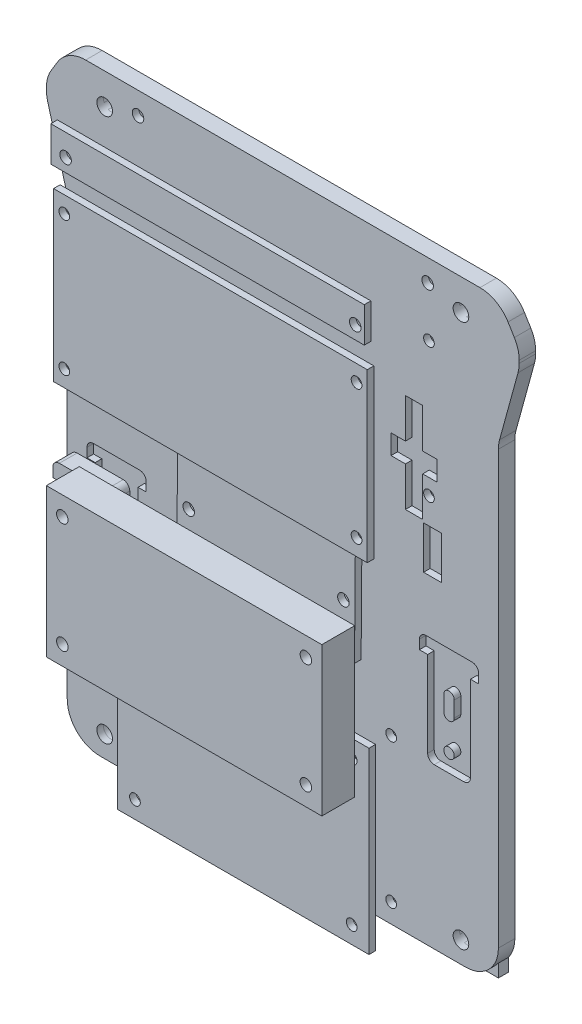
from build123d import *

# Parameters (mm, degrees)
BOSS_EXTRUDE2_DEPTH  = 5
SKETCH4_R            = 1
BATTERY_PACK_DEPTH   = 6
SKETCH5_R            = 1.625
MOTOR_MOUNTS_DEPTH   = 6
SKETCH6_R            = 1.625
MTR_CLTR_DEPTH       = 6
CASTER_R             = 1.625
FRONT_WHEEL_DEPTH    = 6
ANLG_CTLR_R          = 1.625
ANLG_CTLR_1_DEPTH    = 6
TOP_PLATE_R          = 2.3749
CUT_EXTRUDE3_DEPTH   = 6
TOP_PLATE_3_W        = 127
TOP_PLATE_3_H        = 177.8
TOP_PLATE_3_R        = 6.35
TOP_PLATE_3_R_2      = 2.3749
BOSS_EXTRUDE3_DEPTH  = 3
SENSOR_BOARD_R       = 1.75
SENSOR_DEPTH         = 6
SKETCH18_W           = 5.46
SKETCH18_H           = 13
CUT_EXTRUDE5_DEPTH   = 6
SKETCH19_R           = 1.5875
CUT_EXTRUDE6_DEPTH   = 6
BOSS_EXTRUDE5_START  = 10
SKETCH16_3_W         = 57.15
SKETCH16_3_H         = 23.114
SKETCH16_3_R         = 1.5875
BOSS_EXTRUDE5_DEPTH  = 2
BOSS_EXTRUDE6_START  = 10
SKETCH10_3_R         = 1.75
BOSS_EXTRUDE6_DEPTH  = 2
BOSS_EXTRUDE7_START  = 10
SKETCH6_2_W          = 76.36
SKETCH6_2_H          = 54.3
SKETCH6_2_R          = 1.625
BOSS_EXTRUDE7_DEPTH  = 2
BOSS_EXTRUDE8_START  = 10
SKETCH19_3_R         = 1.5875
BOSS_EXTRUDE8_DEPTH  = 5.4
BOSS_EXTRUDE9_START  = 20
SKETCH8_2_W          = 95.3
SKETCH8_2_H          = 50.81
SKETCH8_2_R          = 1.625
BOSS_EXTRUDE9_DEPTH  = 2
BOSS_EXTRUDE10_START = 20
BRD_BOARD_W          = 83.7
BRD_BOARD_H          = 45.1
BRD_BOARD_R          = 1.75
BOSS_EXTRUDE10_DEPTH = 10
BOSS_EXTRUDE11_START = -10
SKETCH7_3_W          = 38
SKETCH7_3_H          = 33
SKETCH7_3_R          = 1.625
BOSS_EXTRUDE11_DEPTH = 2
BOSS_EXTRUDE12_START = 20
SENSOR_BOARD_3_W     = 95.25
SENSOR_BOARD_3_H     = 10.65
SENSOR_BOARD_3_R     = 1.75
BOSS_EXTRUDE12_DEPTH = 2
FPGA_R               = 1.75
CUT_EXTRUDE10_DEPTH  = 36
BRD_BOARD_5_R        = 1.75
CUT_EXTRUDE11_DEPTH  = 11


with BuildPart() as part:
    # Outline1 → Boss-Extrude2 (new body)
    with BuildSketch(Plane.XY):
        with BuildLine():
            Line((-65.5, 141.268437099), (-65.5, 10))
            ThreePointArc((-65.5, 10), (-62.571067812, 2.928932188), (-55.5, 0))
            Line((-55.5, 0), (55.5, 0))
            ThreePointArc((55.5, 0), (62.571067812, 2.928932188), (65.5, 10))
            Line((65.5, 10), (65.5, 141.268437099))
            ThreePointArc((65.5, 141.268437099), (65.589402556, 142.602625355), (65.856011661, 143.912957643))
            Line((65.856011661, 143.912957643), (71.465198975, 164.368437622))
            ThreePointArc((71.465198975, 164.368437622), (71.731808079, 165.67876991), (71.821210635, 167.012958167))
            Line((71.821210635, 167.012958167), (71.821210635, 167.847824973))
            ThreePointArc((71.821210635, 167.847824973), (71.446110508, 170.560996999), (70.348950147, 173.070626791))
            Line((70.348950147, 173.070626791), (68.425788167, 176.210746783))
            ThreePointArc((68.425788167, 176.210746783), (64.785378285, 179.712279271), (59.898048656, 180.987944965))
            Line((59.898048656, 180.987944965), (-59.898048655, 180.987944965))
            ThreePointArc((-59.898048655, 180.987944965), (-64.785378285, 179.712279271), (-68.425788167, 176.210746783))
            Line((-68.425788167, 176.210746783), (-70.348950147, 173.070626791))
            ThreePointArc((-70.348950147, 173.070626791), (-71.446110508, 170.560996999), (-71.821210635, 167.847824973))
            Line((-71.821210635, 167.847824973), (-71.821210635, 167.012958167))
            ThreePointArc((-71.821210635, 167.012958167), (-71.731808079, 165.67876991), (-71.465198975, 164.368437622))
            Line((-71.465198975, 164.368437622), (-65.856011661, 143.912957643))
            ThreePointArc((-65.856011661, 143.912957643), (-65.589402556, 142.602625355), (-65.5, 141.268437099))
        make_face()
    extrude(amount=BOSS_EXTRUDE2_DEPTH)

    # Sketch4 → Battery Pack (cut, through all)
    with BuildSketch(Plane.XY.offset(5)):
        with Locations((0, 105.731791241)):
            Circle(SKETCH4_R)
        with Locations((0, 61.131791241)):
            Circle(SKETCH4_R)
        with Locations((0, 55.681791241)):
            Circle(SKETCH4_R)
        with Locations((0, 111.181791241)):
            Circle(SKETCH4_R)
    extrude(amount=-BATTERY_PACK_DEPTH, mode=Mode.SUBTRACT)

    # Sketch5 → Motor mounts (cut, through all)
    with BuildSketch(Plane.XY.offset(5)):
        Polygon((37.25, 111.277082215), (42.5, 111.277082215), (42.5, 123.277082215), (46.875, 123.277082215), (46.875, 129.277082215), (42.5, 129.277082215), (42.5, 141.277082215), (37.25, 141.277082215), (37.25, 129.277082215), (32.875, 129.277082215), (32.875, 123.277082215), (37.25, 123.277082215), align=None)
        Polygon((-37.25, 141.277082215), (-37.25, 129.277082215), (-32.875, 129.277082215), (-32.875, 123.277082215), (-37.25, 123.277082215), (-37.25, 111.277082215), (-42.5, 111.277082215), (-42.5, 123.277082215), (-46.875, 123.277082215), (-46.875, 129.277082215), (-42.5, 129.277082215), (-42.5, 141.277082215), align=None)
        with Locations((-45.5, 108.277082215)):
            Circle(SKETCH5_R)
        with Locations((-45.5, 99.777082215)):
            Circle(SKETCH5_R)
        with Locations(Location((45.5, 99.777082215, 0), (0, 0, 180))):  # turned: the seam where the file's is
            Circle(SKETCH5_R)
        with Locations(Location((45.5, 108.277082215, 0), (0, 0, 180))):  # turned: the seam where the file's is
            Circle(SKETCH5_R)
    extrude(amount=-MOTOR_MOUNTS_DEPTH, mode=Mode.SUBTRACT)

    # Sketch6 → mtr_cltr (cut, through all)
    with BuildSketch(Plane.XY.offset(5)):
        with Locations((-32.93, 49.68)):
            Circle(SKETCH6_R)
        with Locations((-32.93, 5.88)):
            Circle(SKETCH6_R)
        with Locations((32.93, 5.88)):
            Circle(SKETCH6_R)
        with Locations((32.93, 49.68)):
            Circle(SKETCH6_R)
    extrude(amount=-MTR_CLTR_DEPTH, mode=Mode.SUBTRACT)

    # Caster → Front Wheel (cut, through all)
    with BuildSketch(Plane.XY.offset(5)):
        with Locations((-15.5, 35.5)):
            Circle(CASTER_R)
        with Locations((15.5, 35.5)):
            Circle(CASTER_R)
        with Locations((15.5, 12)):
            Circle(CASTER_R)
        with Locations((-15.5, 12)):
            Circle(CASTER_R)
    extrude(amount=-FRONT_WHEEL_DEPTH, mode=Mode.SUBTRACT)

    # anlg_ctlr → anlg_ctlr.1 (cut, through all)
    with BuildSketch(Plane.XY.offset(5)):
        with Locations((-44.4, 118.467082215)):
            Circle(ANLG_CTLR_R)
        with Locations((44.4, 159.277082215)):
            Circle(ANLG_CTLR_R)
        with Locations((44.4, 118.467082215)):
            Circle(ANLG_CTLR_R)
        with Locations((-44.4, 159.277082215)):
            Circle(ANLG_CTLR_R)
    extrude(amount=-ANLG_CTLR_1_DEPTH, mode=Mode.SUBTRACT)

    # Top PlaTE → Cut-Extrude3 (cut, through all)
    with BuildSketch(Plane.XY):
        with Locations((54.125, 6.474265411)):
            Circle(TOP_PLATE_R)
        with Locations((-54.125, 171.574265411)):
            Circle(TOP_PLATE_R)
        with Locations((54.125, 171.574265411)):
            Circle(TOP_PLATE_R)
        with Locations((-54.125, 6.474265411)):
            Circle(TOP_PLATE_R)
    extrude(amount=CUT_EXTRUDE3_DEPTH, mode=Mode.SUBTRACT)

    # Sensor Board → Sensor (cut, through all)
    with BuildSketch(Plane.XY.offset(5)):
        with Locations((-44, 174.275082215)):
            Circle(SENSOR_BOARD_R)
        with Locations((44, 174.275082215)):
            Circle(SENSOR_BOARD_R)
    extrude(amount=-SENSOR_DEPTH, mode=Mode.SUBTRACT)

    # Sketch18 → Cut-Extrude5 (cut, through all)
    with BuildSketch(Plane.XY):
        with Locations((-45.5, 104.027082215)):
            Rectangle(SKETCH18_W, SKETCH18_H)
        with Locations((45.5, 104.027082215)):
            Rectangle(SKETCH18_W, SKETCH18_H)
    extrude(amount=CUT_EXTRUDE5_DEPTH, mode=Mode.SUBTRACT)

    # Sketch19 → Cut-Extrude6 (cut, through all)
    with BuildSketch(Plane.XY):
        with BuildLine():
            Line((-55, 48.501962253), (-46, 48.501962253))
            ThreePointArc((-46, 48.501962253), (-44.585786438, 49.087748691), (-44, 50.501962253))
            Line((-44, 50.501962253), (-44, 76.501962253))
            Line((-44, 76.501962253), (-57, 76.501962253))
            Line((-57, 76.501962253), (-57, 50.501962253))
            ThreePointArc((-57, 50.501962253), (-56.414213562, 49.087748691), (-55, 48.501962253))
        make_face()
        with Locations((-50.5, 53.841962253)):
            Circle(SKETCH19_R, mode=Mode.SUBTRACT)
        with BuildLine():
            ThreePointArc((-52.0875, 63.821962253), (-50.5, 62.234462253), (-48.9125, 63.821962253))
            Line((-48.9125, 63.821962253), (-48.9125, 68.569720756))
            ThreePointArc((-48.9125, 68.569720756), (-50.5, 70.157220756), (-52.0875, 68.569720756))
            Line((-52.0875, 68.569720756), (-52.0875, 63.821962253))
        make_face(mode=Mode.SUBTRACT)
        with BuildLine():
            Line((-59.5, 76.501962253), (-57, 76.501962253))
            Line((-57, 76.501962253), (-44, 76.501962253))
            Line((-44, 76.501962253), (-41.5, 76.501962253))
            Line((-41.5, 76.501962253), (-41.5, 79.264462253))
            ThreePointArc((-41.5, 79.264462253), (-42.085786438, 80.678675816), (-43.5, 81.264462253))
            Line((-43.5, 81.264462253), (-57.5, 81.264462253))
            ThreePointArc((-57.5, 81.264462253), (-58.914213562, 80.678675816), (-59.5, 79.264462253))
            Line((-59.5, 79.264462253), (-59.5, 76.501962253))
        make_face()
        with BuildLine():
            ThreePointArc((41.5, 79.264462253), (42.085786438, 80.678675816), (43.5, 81.264462253))
            Line((43.5, 81.264462253), (57.5, 81.264462253))
            ThreePointArc((57.5, 81.264462253), (58.914213562, 80.678675816), (59.5, 79.264462253))
            Line((59.5, 79.264462253), (59.5, 76.501962253))
            Line((59.5, 76.501962253), (41.5, 76.501962253))
            Line((41.5, 76.501962253), (41.5, 79.264462253))
        make_face()
        with BuildLine():
            Line((57, 76.501962253), (44, 76.501962253))
            Line((44, 76.501962253), (44, 50.501962253))
            ThreePointArc((44, 50.501962253), (44.585786438, 49.087748691), (46, 48.501962253))
            Line((46, 48.501962253), (55, 48.501962253))
            ThreePointArc((55, 48.501962253), (56.414213562, 49.087748691), (57, 50.501962253))
            Line((57, 50.501962253), (57, 76.501962253))
        make_face()
        with Locations((50.5, 53.841962253)):
            Circle(SKETCH19_R, mode=Mode.SUBTRACT)
        with BuildLine():
            Line((48.9125, 63.821962253), (48.9125, 68.569720756))
            ThreePointArc((48.9125, 68.569720756), (50.5, 70.157220756), (52.0875, 68.569720756))
            Line((52.0875, 68.569720756), (52.0875, 63.821962253))
            ThreePointArc((52.0875, 63.821962253), (50.5, 62.234462253), (48.9125, 63.821962253))
        make_face(mode=Mode.SUBTRACT)
    extrude(amount=CUT_EXTRUDE6_DEPTH, mode=Mode.SUBTRACT)


with BuildPart() as body_2:
    # Top PlaTE_3 → Boss-Extrude3 (new body)
    with BuildSketch(Plane.XY):
        with Locations((0, 89.024265411)):
            Rectangle(TOP_PLATE_3_W, TOP_PLATE_3_H)
        with Locations((-53.34, 50.924265411)):
            Circle(TOP_PLATE_3_R, mode=Mode.SUBTRACT)
        with Locations((54.125, 6.474265411)):
            Circle(TOP_PLATE_3_R_2, mode=Mode.SUBTRACT)
        with Locations((-54.125, 171.574265411)):
            Circle(TOP_PLATE_3_R_2, mode=Mode.SUBTRACT)
        with Locations((54.125, 171.574265411)):
            Circle(TOP_PLATE_3_R_2, mode=Mode.SUBTRACT)
        with Locations((-54.125, 6.474265411)):
            Circle(TOP_PLATE_3_R_2, mode=Mode.SUBTRACT)
    extrude(amount=BOSS_EXTRUDE3_DEPTH)

    # FPGA → Cut-Extrude10 (cut, through all)
    with BuildSketch(Plane.XY):
        with Locations((-34, 169.658814415)):
            Circle(FPGA_R)
        with Locations((34, 169.658814415)):
            Circle(FPGA_R)
        with Locations((34, 101.658814415)):
            Circle(FPGA_R)
        with Locations((-34, 101.658814415)):
            Circle(FPGA_R)
    extrude(amount=CUT_EXTRUDE10_DEPTH, mode=Mode.SUBTRACT)

    # brd_board_5 → Cut-Extrude11 (cut, through all)
    with BuildSketch(Plane.XY.offset(5)):
        with Locations((37, 53.718812762)):
            Circle(BRD_BOARD_5_R)
        with Locations((-37, 53.718812762)):
            Circle(BRD_BOARD_5_R)
        with Locations((-37, 87.218812762)):
            Circle(BRD_BOARD_5_R)
        with Locations((37, 87.218812762)):
            Circle(BRD_BOARD_5_R)
    extrude(amount=-CUT_EXTRUDE11_DEPTH, mode=Mode.SUBTRACT)


with BuildPart() as body_3:
    # Sketch16_3 → Boss-Extrude5 (new body)
    with BuildSketch(Plane.XY.offset(BOSS_EXTRUDE5_START)):
        with Locations((0, 36.625433673)):
            Rectangle(SKETCH16_3_W, SKETCH16_3_H)
        with Locations((-25.908, 45.007433673)):
            Circle(SKETCH16_3_R, mode=Mode.SUBTRACT)
        with Locations((25.908, 45.007433673)):
            Circle(SKETCH16_3_R, mode=Mode.SUBTRACT)
        with Locations((25.908, 28.243433673)):
            Circle(SKETCH16_3_R, mode=Mode.SUBTRACT)
        with Locations((-25.908, 28.243433673)):
            Circle(SKETCH16_3_R, mode=Mode.SUBTRACT)
    extrude(amount=BOSS_EXTRUDE5_DEPTH)


with BuildPart() as body_4:
    # Sketch10_3 → Boss-Extrude6 (new body)
    with BuildSketch(Plane.XY.offset(BOSS_EXTRUDE6_START)):
        Polygon((-25.211498717, 70.476976171), (-15.961785964, 70.404079055), (-16.011040772, 64.154273141), (-3.761421181, 64.057733717), (-3.712166372, 70.307539631), (15.787228079, 70.15386463), (15.771466541, 68.153926737), (24.771187057, 68.082999813), (24.786948596, 70.082937706), (28.786824381, 70.051414628), (29.306955155, 136.049365081), (26.557040553, 136.071037197), (23.703801948, 138.843609011), (-9.295173278, 139.103674398), (-12.191756114, 136.376417008), (-24.691367942, 136.474926624), align=None)
        with Locations((25.405144609, 85.078531515)):
            Circle(SKETCH10_3_R, mode=Mode.SUBTRACT)
        with Locations((-21.593395865, 85.448927673)):
            Circle(SKETCH10_3_R, mode=Mode.SUBTRACT)
        with Locations((-6.686016333, 137.083049486)):
            Circle(SKETCH10_3_R, mode=Mode.SUBTRACT)
        with Locations((21.813098635, 136.858447561)):
            Circle(SKETCH10_3_R, mode=Mode.SUBTRACT)
    extrude(amount=BOSS_EXTRUDE6_DEPTH)


with BuildPart() as body_5:
    # Sketch6_2 → Boss-Extrude7 (new body)
    with BuildSketch(Plane.XY.offset(5).offset(BOSS_EXTRUDE7_START)):
        with Locations((0, 27.78)):
            Rectangle(SKETCH6_2_W, SKETCH6_2_H)
        with Locations((-32.93, 49.68)):
            Circle(SKETCH6_2_R, mode=Mode.SUBTRACT)
        with Locations((32.93, 49.68)):
            Circle(SKETCH6_2_R, mode=Mode.SUBTRACT)
        with Locations((32.93, 5.88)):
            Circle(SKETCH6_2_R, mode=Mode.SUBTRACT)
        with Locations((-32.93, 5.88)):
            Circle(SKETCH6_2_R, mode=Mode.SUBTRACT)
    extrude(amount=BOSS_EXTRUDE7_DEPTH)


with BuildPart() as body_6:
    # Sketch19_3 → Boss-Extrude8 (new body)
    with BuildSketch(Plane.XY.offset(BOSS_EXTRUDE8_START)):
        with BuildLine():
            Line((-55, 48.501962253), (-46, 48.501962253))
            ThreePointArc((-46, 48.501962253), (-44.585786438, 49.087748691), (-44, 50.501962253))
            Line((-44, 50.501962253), (-44, 76.501962253))
            Line((-44, 76.501962253), (-57, 76.501962253))
            Line((-57, 76.501962253), (-57, 50.501962253))
            ThreePointArc((-57, 50.501962253), (-56.414213562, 49.087748691), (-55, 48.501962253))
        make_face()
        with Locations((-50.5, 53.841962253)):
            Circle(SKETCH19_3_R, mode=Mode.SUBTRACT)
        with BuildLine():
            ThreePointArc((-52.0875, 63.821962253), (-50.5, 62.234462253), (-48.9125, 63.821962253))
            Line((-48.9125, 63.821962253), (-48.9125, 68.569720756))
            ThreePointArc((-48.9125, 68.569720756), (-50.5, 70.157220756), (-52.0875, 68.569720756))
            Line((-52.0875, 68.569720756), (-52.0875, 63.821962253))
        make_face(mode=Mode.SUBTRACT)
        with BuildLine():
            Line((-59.5, 76.501962253), (-57, 76.501962253))
            Line((-57, 76.501962253), (-44, 76.501962253))
            Line((-44, 76.501962253), (-41.5, 76.501962253))
            Line((-41.5, 76.501962253), (-41.5, 79.264462253))
            ThreePointArc((-41.5, 79.264462253), (-42.085786438, 80.678675816), (-43.5, 81.264462253))
            Line((-43.5, 81.264462253), (-57.5, 81.264462253))
            ThreePointArc((-57.5, 81.264462253), (-58.914213562, 80.678675816), (-59.5, 79.264462253))
            Line((-59.5, 79.264462253), (-59.5, 76.501962253))
        make_face()
    extrude(amount=BOSS_EXTRUDE8_DEPTH)


with BuildPart() as body_7:
    # Sketch8_2 → Boss-Extrude9 (new body)
    with BuildSketch(Plane.XY.offset(5).offset(BOSS_EXTRUDE9_START)):
        with Locations((0, 138.872082215)):
            Rectangle(SKETCH8_2_W, SKETCH8_2_H)
        with Locations((44.4, 118.467082215)):
            Circle(SKETCH8_2_R, mode=Mode.SUBTRACT)
        with Locations((-44.4, 118.467082215)):
            Circle(SKETCH8_2_R, mode=Mode.SUBTRACT)
        with Locations((-44.4, 159.277082215)):
            Circle(SKETCH8_2_R, mode=Mode.SUBTRACT)
        with Locations((44.4, 159.277082215)):
            Circle(SKETCH8_2_R, mode=Mode.SUBTRACT)
    extrude(amount=BOSS_EXTRUDE9_DEPTH)


with BuildPart() as body_8:
    # brd_board → Boss-Extrude10 (new body)
    with BuildSketch(Plane.XY.offset(5).offset(BOSS_EXTRUDE10_START)):
        with Locations((0, 70.468812762)):
            Rectangle(BRD_BOARD_W, BRD_BOARD_H)
        with Locations((37, 53.718812762)):
            Circle(BRD_BOARD_R, mode=Mode.SUBTRACT)
        with Locations((-37, 53.718812762)):
            Circle(BRD_BOARD_R, mode=Mode.SUBTRACT)
        with Locations((-37, 87.218812762)):
            Circle(BRD_BOARD_R, mode=Mode.SUBTRACT)
        with Locations((37, 87.218812762)):
            Circle(BRD_BOARD_R, mode=Mode.SUBTRACT)
    extrude(amount=BOSS_EXTRUDE10_DEPTH)


with BuildPart() as body_9:
    # Sketch7_3 → Boss-Extrude11 (new body)
    with BuildSketch(Plane.XY.offset(5).offset(BOSS_EXTRUDE11_START)):
        with Locations((0, 23.75)):
            Rectangle(SKETCH7_3_W, SKETCH7_3_H)
        with Locations((-15.5, 35.5)):
            Circle(SKETCH7_3_R, mode=Mode.SUBTRACT)
        with Locations((15.5, 35.5)):
            Circle(SKETCH7_3_R, mode=Mode.SUBTRACT)
        with Locations((15.5, 12)):
            Circle(SKETCH7_3_R, mode=Mode.SUBTRACT)
        with Locations((-15.5, 12)):
            Circle(SKETCH7_3_R, mode=Mode.SUBTRACT)
    extrude(amount=BOSS_EXTRUDE11_DEPTH)


with BuildPart() as body_10:
    # Sensor Board_3 → Boss-Extrude12 (new body)
    with BuildSketch(Plane.XY.offset(5).offset(BOSS_EXTRUDE12_START)):
        with Locations((-0.875, 175.600082215)):
            Rectangle(SENSOR_BOARD_3_W, SENSOR_BOARD_3_H)
        with Locations((-44, 174.275082215)):
            Circle(SENSOR_BOARD_3_R, mode=Mode.SUBTRACT)
        with Locations((44, 174.275082215)):
            Circle(SENSOR_BOARD_3_R, mode=Mode.SUBTRACT)
    extrude(amount=BOSS_EXTRUDE12_DEPTH)


solid = Compound([part.part, body_2.part, body_3.part, body_4.part, body_5.part, body_6.part, body_7.part, body_8.part, body_9.part, body_10.part])
